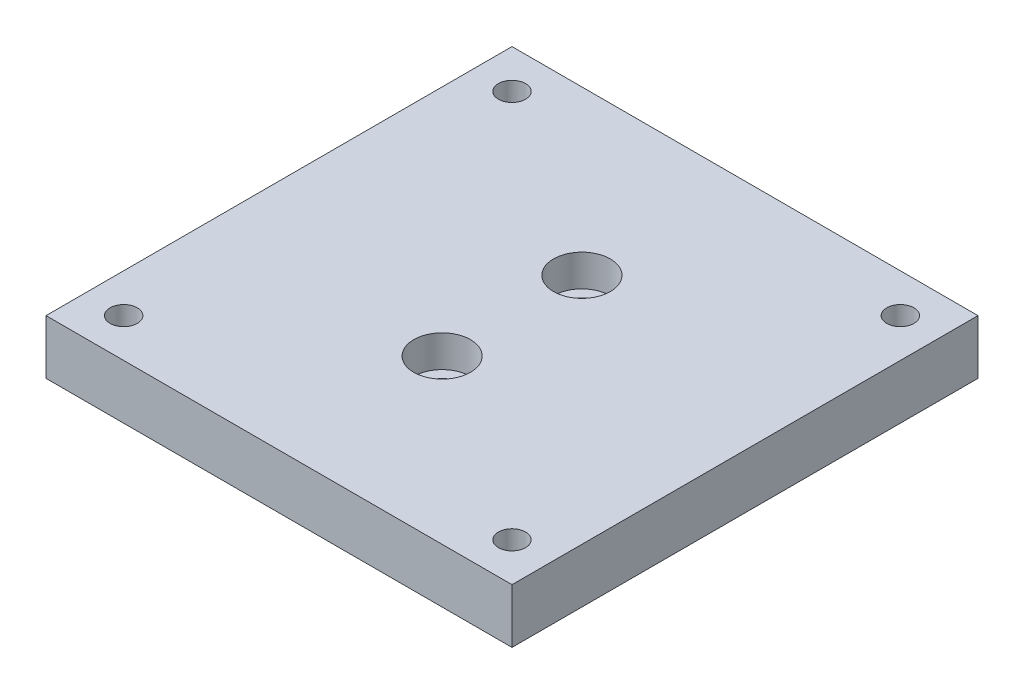
from build123d import *

# Parameters (mm, degrees)
SKETCH_2_W          = 60
SKETCH_2_H          = 60
EXTRUDE_1_DEPTH     = 7
CUT_EXTRUDE_1_DEPTH = 2.6
CUT_EXTRUDE_2_REACH = 9
SKETCH_4_R          = 1.75
SKETCH_5_R          = 3.65
CUT_EXTRUDE_3_DEPTH = 4.1
CUT_EXTRUDE_4_REACH = 4.9
SKETCH_6_R          = 2.25


with BuildPart() as part:
    # 草圖2 → 填料-伸長1 (new body)
    with BuildSketch(Plane(origin=(0, 0, 0), x_dir=(1, 0, 0), z_dir=(0, 1, 0))):
        Rectangle(SKETCH_2_W, SKETCH_2_H)
    extrude(amount=EXTRUDE_1_DEPTH)

    # 草圖3 → 除料-伸長1 (cut)
    with BuildSketch(Plane.XZ):
        Polygon((-21.824573519, 25), (-23.41228676, 27.75), (-26.58771324, 27.75), (-28.175426481, 25), (-26.58771324, 22.25), (-23.41228676, 22.25), align=None)
        Polygon((23.41228676, 22.25), (21.824573519, 25), (23.41228676, 27.75), (26.58771324, 27.75), (28.175426481, 25), (26.58771324, 22.25), align=None)
        Polygon((21.824573519, -25), (23.41228676, -27.75), (26.58771324, -27.75), (28.175426481, -25), (26.58771324, -22.25), (23.41228676, -22.25), align=None)
        Polygon((-23.41228676, -22.25), (-21.824573519, -25), (-23.41228676, -27.75), (-26.58771324, -27.75), (-28.175426481, -25), (-26.58771324, -22.25), align=None)
    extrude(amount=-CUT_EXTRUDE_1_DEPTH, mode=Mode.SUBTRACT)

    # 草圖4 → 除料-伸長2 (cut, up to next)
    with BuildSketch(Plane(origin=(0, 7, 0), x_dir=(1, 0, 0), z_dir=(0, 1, 0)), mode=Mode.PRIVATE) as cut_extrude_2_sk1:
        with Locations((-25, 25)):
            Circle(SKETCH_4_R)
    cut_extrude_2_tool1 = extrude(cut_extrude_2_sk1.sketch, amount=-CUT_EXTRUDE_2_REACH, mode=Mode.PRIVATE) & part.part
    add(cut_extrude_2_tool1.solids().sort_by_distance((-25, 7, -25))[0], mode=Mode.SUBTRACT)
    # 草圖4 → 除料-伸長2 (cut, up to next)
    with BuildSketch(Plane(origin=(0, 7, 0), x_dir=(1, 0, 0), z_dir=(0, 1, 0)), mode=Mode.PRIVATE) as cut_extrude_2_sk2:
        with Locations((25, 25)):
            Circle(SKETCH_4_R)
    cut_extrude_2_tool2 = extrude(cut_extrude_2_sk2.sketch, amount=-CUT_EXTRUDE_2_REACH, mode=Mode.PRIVATE) & part.part
    add(cut_extrude_2_tool2.solids().sort_by_distance((25, 7, -25))[0], mode=Mode.SUBTRACT)
    # 草圖4 → 除料-伸長2 (cut, up to next)
    with BuildSketch(Plane(origin=(0, 7, 0), x_dir=(1, 0, 0), z_dir=(0, 1, 0)), mode=Mode.PRIVATE) as cut_extrude_2_sk3:
        with Locations((25, -25)):
            Circle(SKETCH_4_R)
    cut_extrude_2_tool3 = extrude(cut_extrude_2_sk3.sketch, amount=-CUT_EXTRUDE_2_REACH, mode=Mode.PRIVATE) & part.part
    add(cut_extrude_2_tool3.solids().sort_by_distance((25, 7, 25))[0], mode=Mode.SUBTRACT)
    # 草圖4 → 除料-伸長2 (cut, up to next)
    with BuildSketch(Plane(origin=(0, 7, 0), x_dir=(1, 0, 0), z_dir=(0, 1, 0)), mode=Mode.PRIVATE) as cut_extrude_2_sk4:
        with Locations((-25, -25)):
            Circle(SKETCH_4_R)
    cut_extrude_2_tool4 = extrude(cut_extrude_2_sk4.sketch, amount=-CUT_EXTRUDE_2_REACH, mode=Mode.PRIVATE) & part.part
    add(cut_extrude_2_tool4.solids().sort_by_distance((-25, 7, 25))[0], mode=Mode.SUBTRACT)

    # 草圖5 → 除料-伸長3 (cut)
    with BuildSketch(Plane(origin=(0, 7, 0), x_dir=(1, 0, 0), z_dir=(0, 1, 0))):
        with Locations((0, 9)):
            Circle(SKETCH_5_R)
        with Locations((0, -9)):
            Circle(SKETCH_5_R)
    extrude(amount=-CUT_EXTRUDE_3_DEPTH, mode=Mode.SUBTRACT)

    # 草圖6 → 除料-伸長4 (cut, up to next)
    with BuildSketch(Plane(origin=(0, 2.9, 0), x_dir=(1, 0, 0), z_dir=(0, 1, 0)), mode=Mode.PRIVATE) as cut_extrude_4_sk1:
        with Locations((0, 9)):
            Circle(SKETCH_6_R)
    cut_extrude_4_tool1 = extrude(cut_extrude_4_sk1.sketch, amount=-CUT_EXTRUDE_4_REACH, mode=Mode.PRIVATE) & part.part
    add(cut_extrude_4_tool1.solids().sort_by_distance((0, 2.9, -9))[0], mode=Mode.SUBTRACT)
    # 草圖6 → 除料-伸長4 (cut, up to next)
    with BuildSketch(Plane(origin=(0, 2.9, 0), x_dir=(1, 0, 0), z_dir=(0, 1, 0)), mode=Mode.PRIVATE) as cut_extrude_4_sk2:
        with Locations((0, -9)):
            Circle(SKETCH_6_R)
    cut_extrude_4_tool2 = extrude(cut_extrude_4_sk2.sketch, amount=-CUT_EXTRUDE_4_REACH, mode=Mode.PRIVATE) & part.part
    add(cut_extrude_4_tool2.solids().sort_by_distance((0, 2.9, 9))[0], mode=Mode.SUBTRACT)


solid = part.part
